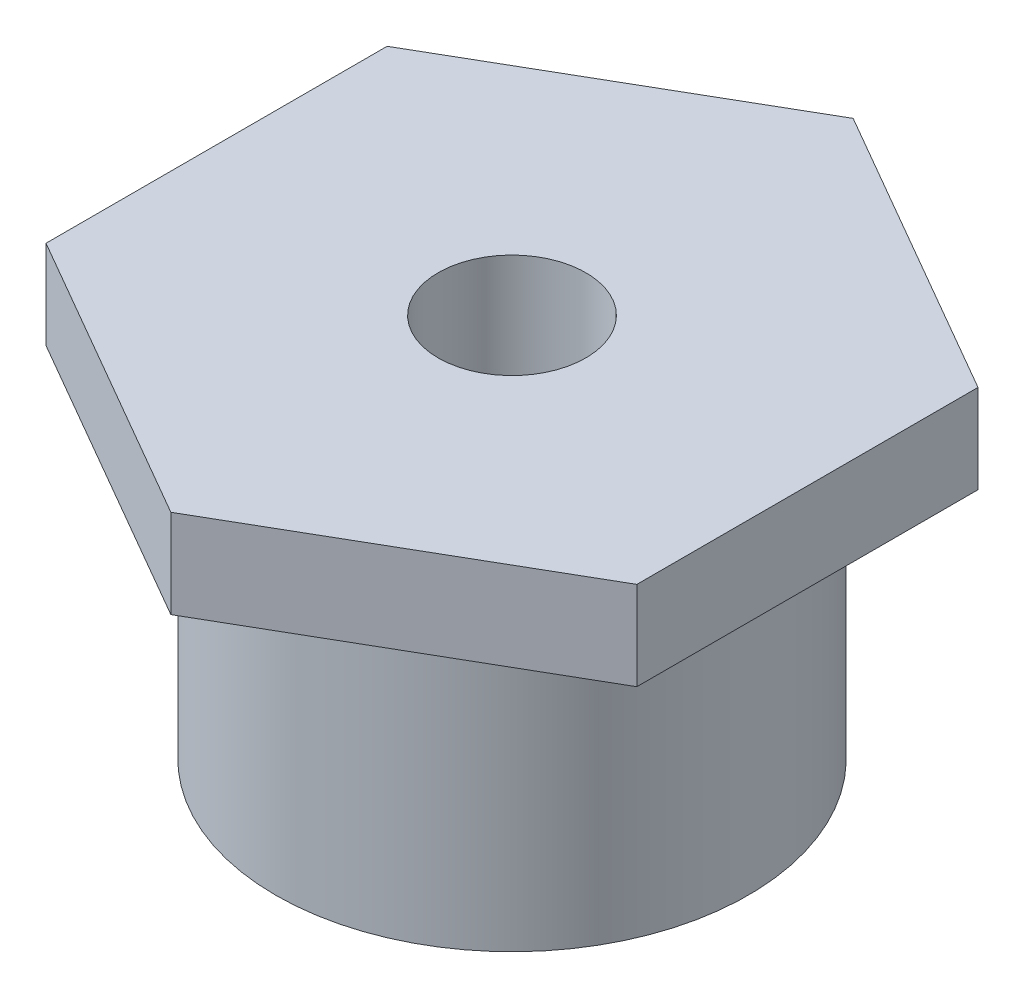
from build123d import *

# Parameters (mm, degrees)
SKETCH1_R           = 40
BOSS_EXTRUDE1_DEPTH = 50
BOSS_EXTRUDE2_DEPTH = 15
SKETCH4_R           = 12.5
CUT_EXTRUDE1_DEPTH  = 35


with BuildPart() as part:
    # Sketch1 → Boss-Extrude1 (new body)
    with BuildSketch(Plane(origin=(0, 0, 0), x_dir=(1, 0, 0), z_dir=(0, 1, 0))):
        Circle(SKETCH1_R)
    extrude(amount=BOSS_EXTRUDE1_DEPTH)

    # Sketch2 → Boss-Extrude2 (add)
    with BuildSketch(Plane(origin=(0, 50, 0), x_dir=(1, 0, 0), z_dir=(0, 1, 0))):
        Polygon((0, -57.735026919), (50, -28.867513459), (50, 28.867513459), (0, 57.735026919), (-50, 28.867513459), (-50, -28.867513459), align=None)
    extrude(amount=BOSS_EXTRUDE2_DEPTH)

    # Sketch4 → Cut-Extrude1 (cut)
    with BuildSketch(Plane(origin=(0, 65, 0), x_dir=(1, 0, 0), z_dir=(0, 1, 0))):
        Circle(SKETCH4_R)
    extrude(amount=-CUT_EXTRUDE1_DEPTH, mode=Mode.SUBTRACT)


solid = part.part
